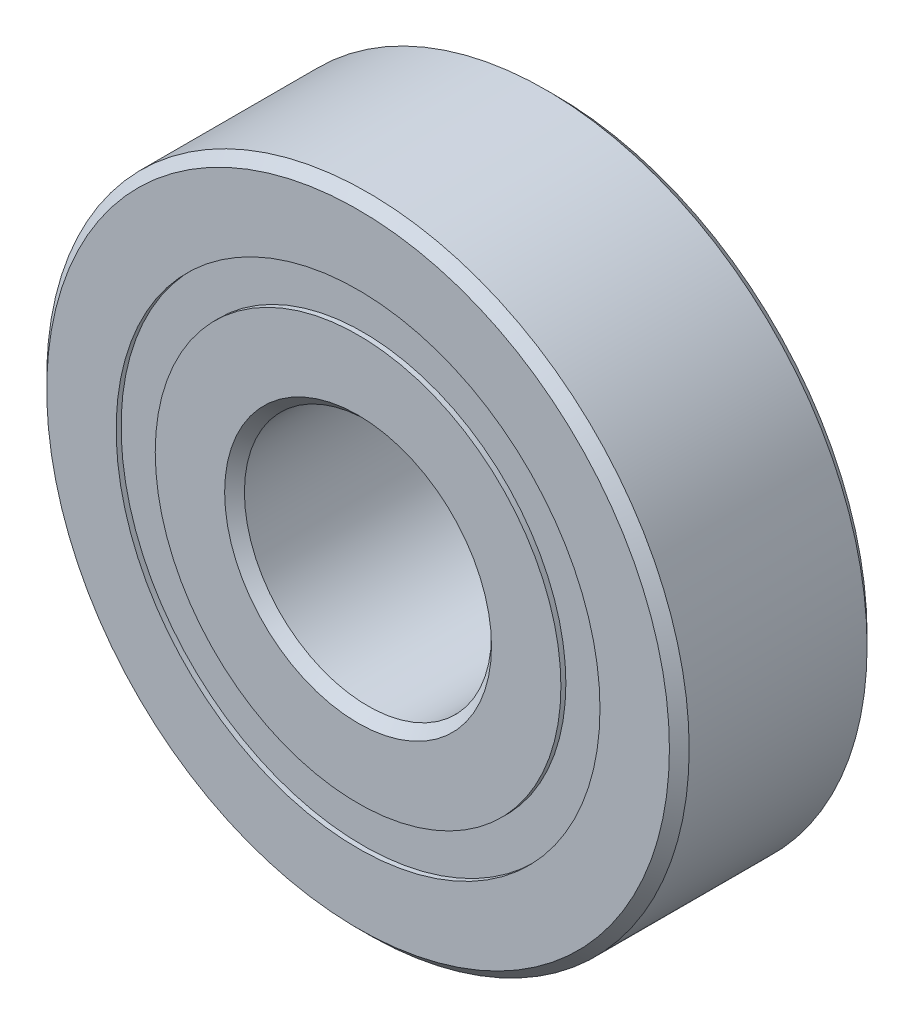
from build123d import *

# Parameters (mm, degrees)
CIRPATTERN1_COUNT = 12


with BuildPart() as part:
    # Sketch1 → Revolve1 (revolve)
    with BuildSketch(Plane(origin=(0, 0, 0), x_dir=(0, 0, -1), z_dir=(1, 0, 0))):
        with BuildLine():
            Line((3.6, 13), (-3.6, 13))
            Line((-3.6, 13), (-4, 12.6))
            Line((-4, 12.6), (-1.777777778, 12.6))
            Line((-1.777777778, 12.6), (-1.777777778, 9.791208791))
            ThreePointArc((-1.777777778, 9.791208791), (0, 10.945894442), (1.777777778, 9.791208791))
            Line((1.777777778, 9.791208791), (1.777777778, 12.6))
            Line((1.777777778, 12.6), (4, 12.6))
            Line((4, 12.6), (3.6, 13))
        make_face()
    revolve(axis=Axis((0, 0, 4), (0, 0, -1)))


with BuildPart() as body_2:
    # Sketch3 → Revolve3 (revolve)
    with BuildSketch(Plane(origin=(0, 0, 0), x_dir=(0, 0, -1), z_dir=(1, 0, 0))):
        with BuildLine():
            Line((-4, 5.4), (-4, 8.208791209))
            Line((-4, 8.208791209), (-1.777777778, 8.208791209))
            ThreePointArc((-1.777777778, 8.208791209), (0, 7.054105558), (1.777777778, 8.208791209))
            Line((1.777777778, 8.208791209), (4, 8.208791209))
            Line((4, 8.208791209), (4, 5.4))
            Line((4, 5.4), (3.6, 5))
            Line((3.6, 5), (-3.6, 5))
            Line((-3.6, 5), (-4, 5.4))
        make_face()
    revolve(axis=Axis((0, 0, 4), (0, 0, -1)))


with BuildPart() as body_3:
    # Sketch4 → Revolve4 (revolve)
    with BuildSketch(Plane(origin=(0, 0, 0), x_dir=(0, 0, -1), z_dir=(1, 0, 0))):
        with BuildLine():
            Line((-1.945894442, 9), (1.945894442, 9))
            ThreePointArc((1.945894442, 9), (0, 10.945894442), (-1.945894442, 9))
        make_face()
    revolve(axis=Axis((0, 9, 1.945894442), (0, 0, -1)))


with BuildPart() as cirpattern1_1:
    # CirPattern1: pattern copy
    add(body_3.part.rotate(Axis((0, 0, -4), (0, 0, 1)), 1 * 360 / CIRPATTERN1_COUNT))


with BuildPart() as cirpattern1_2:
    # CirPattern1: pattern copy
    add(body_3.part.rotate(Axis((0, 0, -4), (0, 0, 1)), 2 * 360 / CIRPATTERN1_COUNT))


with BuildPart() as cirpattern1_3:
    # CirPattern1: pattern copy
    add(body_3.part.rotate(Axis((0, 0, -4), (0, 0, 1)), 3 * 360 / CIRPATTERN1_COUNT))


with BuildPart() as cirpattern1_4:
    # CirPattern1: pattern copy
    add(body_3.part.rotate(Axis((0, 0, -4), (0, 0, 1)), 4 * 360 / CIRPATTERN1_COUNT))


with BuildPart() as cirpattern1_5:
    # CirPattern1: pattern copy
    add(body_3.part.rotate(Axis((0, 0, -4), (0, 0, 1)), 5 * 360 / CIRPATTERN1_COUNT))


with BuildPart() as cirpattern1_6:
    # CirPattern1: pattern copy
    add(body_3.part.rotate(Axis((0, 0, -4), (0, 0, 1)), 6 * 360 / CIRPATTERN1_COUNT))


with BuildPart() as cirpattern1_7:
    # CirPattern1: pattern copy
    add(body_3.part.rotate(Axis((0, 0, -4), (0, 0, 1)), 7 * 360 / CIRPATTERN1_COUNT))


with BuildPart() as cirpattern1_8:
    # CirPattern1: pattern copy
    add(body_3.part.rotate(Axis((0, 0, -4), (0, 0, 1)), 8 * 360 / CIRPATTERN1_COUNT))


with BuildPart() as cirpattern1_9:
    # CirPattern1: pattern copy
    add(body_3.part.rotate(Axis((0, 0, -4), (0, 0, 1)), 9 * 360 / CIRPATTERN1_COUNT))


with BuildPart() as cirpattern1_10:
    # CirPattern1: pattern copy
    add(body_3.part.rotate(Axis((0, 0, -4), (0, 0, 1)), 10 * 360 / CIRPATTERN1_COUNT))


with BuildPart() as cirpattern1_11:
    # CirPattern1: pattern copy
    add(body_3.part.rotate(Axis((0, 0, -4), (0, 0, 1)), 11 * 360 / CIRPATTERN1_COUNT))


with BuildPart() as body_15:
    # Sketch6 → Revolve5 (revolve)
    with BuildSketch(Plane(origin=(0, 0, 0), x_dir=(0, 0, -1), z_dir=(1, 0, 0))):
        with BuildLine():
            Line((-3.8, 9.79), (-4, 9.79))
            Line((-4, 9.79), (-4, 12.6))
            Line((-4, 12.6), (4, 12.6))
            Line((4, 12.6), (4, 9.79))
            Line((4, 9.79), (3.8, 9.79))
            Line((3.8, 9.79), (3.8, 8.21))
            Line((3.8, 8.21), (1.945894442, 8.21))
            Line((1.945894442, 8.21), (1.945894442, 9.126470635))
            ThreePointArc((1.945894442, 9.126470635), (0, 10.95), (-1.945894442, 9.126470635))
            Line((-1.945894442, 9.126470635), (-1.945894442, 8.21))
            Line((-1.945894442, 8.21), (-3.8, 8.21))
            Line((-3.8, 8.21), (-3.8, 9.79))
        make_face()
    revolve(axis=Axis((0, 0, 4), (0, 0, -1)))


solid = Compound([part.part, body_2.part, body_3.part, cirpattern1_1.part, cirpattern1_2.part, cirpattern1_3.part, cirpattern1_4.part, cirpattern1_5.part, cirpattern1_6.part, cirpattern1_7.part, cirpattern1_8.part, cirpattern1_9.part, cirpattern1_10.part, cirpattern1_11.part, body_15.part])
